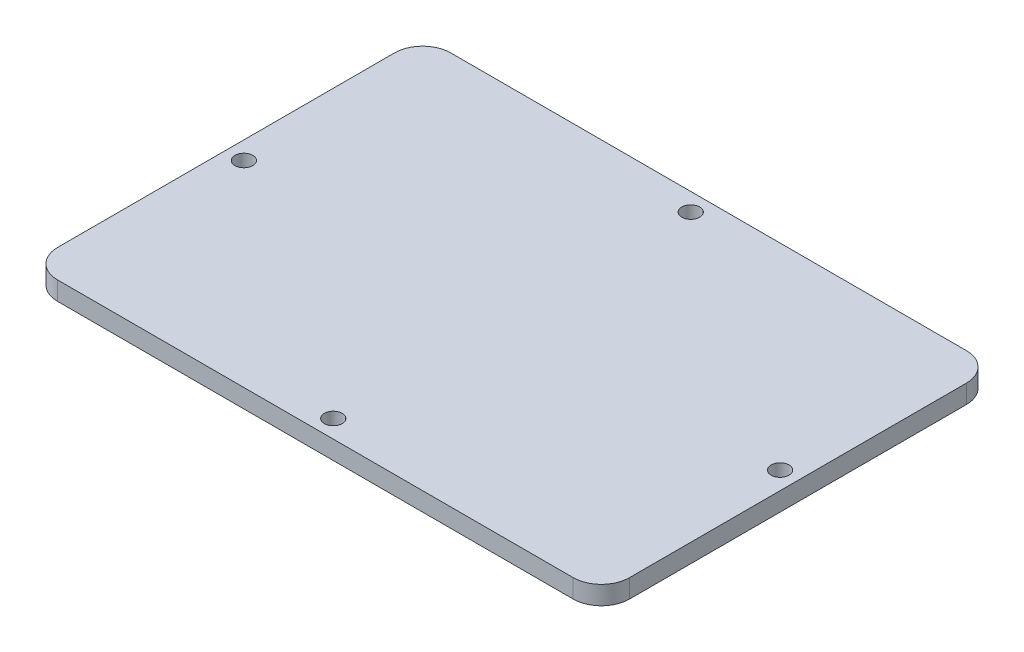
from build123d import *

# Parameters (mm, degrees)
SKETCH1_W           = 101.6
SKETCH1_H           = 69.85
BOSS_EXTRUDE1_DEPTH = 3.302
SKETCH4_R           = 1.5875
CUT_EXTRUDE1_DEPTH  = 4.302
FILLET1_R           = 5


with BuildPart() as part:
    # Sketch1 → Boss-Extrude1 (new body)
    with BuildSketch(Plane(origin=(0, 0, 0), x_dir=(1, 0, 0), z_dir=(0, 1, 0))):
        Rectangle(SKETCH1_W, SKETCH1_H)
    extrude(amount=BOSS_EXTRUDE1_DEPTH)

    # Sketch4 → Cut-Extrude1 (cut, through all)
    with BuildSketch(Plane(origin=(0, 0, 0), x_dir=(-1, 0, 0), z_dir=(0, -1, 0))):
        with Locations((0, 31.75)):
            Circle(SKETCH4_R)
        with Locations((-47.625, 0)):
            Circle(SKETCH4_R)
        with Locations((0, -31.75)):
            Circle(SKETCH4_R)
        with Locations((47.625, 0)):
            Circle(SKETCH4_R)
    extrude(amount=-CUT_EXTRUDE1_DEPTH, mode=Mode.SUBTRACT)

    # Fillet1
    fillet1_edges = [part.edges().sort_by_distance(p)[0] for p in [
        (50.8, 1.651, 34.925),
        (-50.8, 1.651, 34.925),
        (-50.8, 1.651, -34.925),
        (50.8, 1.651, -34.925),
    ]]
    fillet(fillet1_edges, radius=FILLET1_R)


solid = part.part
